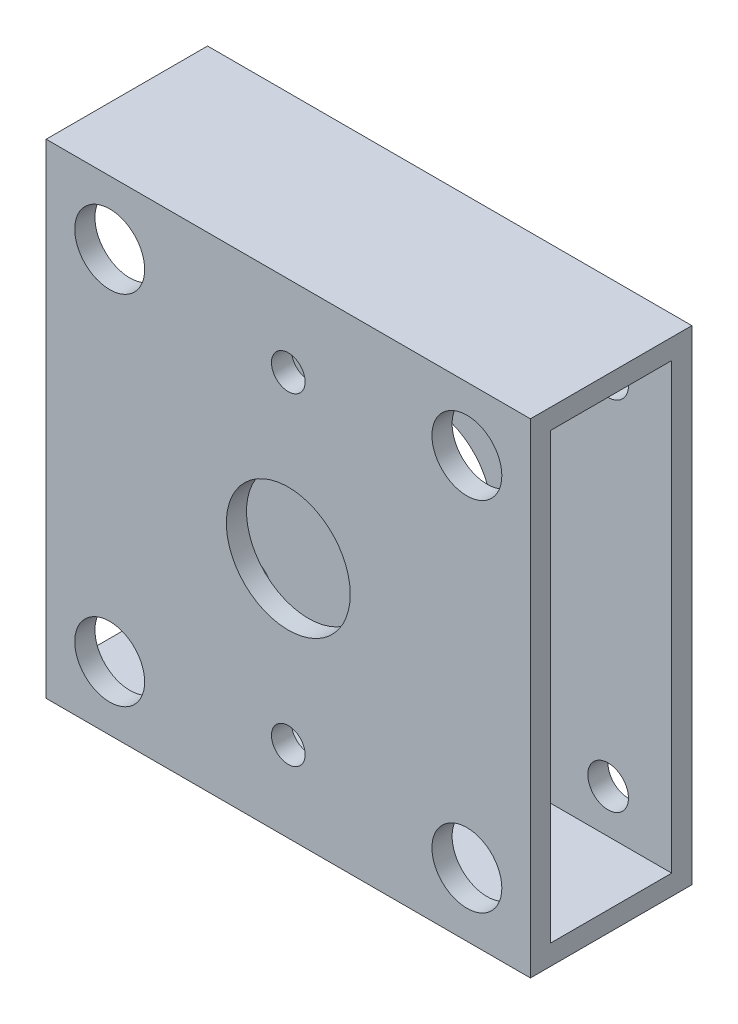
from build123d import *

# Parameters (mm, degrees)
SKETCH1_W                                       = 76.2
SKETCH1_H                                       = 76.2
BOSS_EXTRUDE1_DEPTH                             = 12.7
SKETCH2_W                                       = 19.05
SKETCH2_H                                       = 69.85
CUT_EXTRUDE1_DEPTH                              = 77.2
SKETCH4_R                                       = 9.75
SKETCH4_R_2                                     = 2.2
SKETCH4_R_3                                     = 2.368967754
SKETCH4_R_4                                     = 2.114206927
SKETCH4_R_5                                     = 2.315385773
SKETCH4_R_6                                     = 1.799630575
CUT_EXTRUDE2_DEPTH                              = 26.4
CBORE_FOR_M6_SOCKET_HEAD_CAP_SCREW1_D           = 6.4
CBORE_FOR_M6_SOCKET_HEAD_CAP_SCREW1_CBORE_D     = 11
CBORE_FOR_M6_SOCKET_HEAD_CAP_SCREW1_CBORE_DEPTH = 6.4
CUT_EXTRUDE3_REACH                              = 27.4
SKETCH8_R                                       = 3.81
CBORE_FOR_M5_SOCKET_HEAD_CAP_SCREW3_D           = 5.3
CBORE_FOR_M5_SOCKET_HEAD_CAP_SCREW3_CBORE_D     = 10
CBORE_FOR_M5_SOCKET_HEAD_CAP_SCREW3_CBORE_DEPTH = 5.4


with BuildPart() as part:
    # Sketch1 → Boss-Extrude1 (new body, symmetric)
    with BuildSketch(Plane.XY):
        Rectangle(SKETCH1_W, SKETCH1_H)
    extrude(amount=BOSS_EXTRUDE1_DEPTH, both=True)

    # Sketch2 → Cut-Extrude1 (cut, through all)
    with BuildSketch(Plane(origin=(38.1, 0, 0), x_dir=(0, 0, -1), z_dir=(1, 0, 0))):
        Rectangle(SKETCH2_W, SKETCH2_H)
    extrude(amount=-CUT_EXTRUDE1_DEPTH, mode=Mode.SUBTRACT)

    # Sketch4 → Cut-Extrude2 (cut, through all)
    with BuildSketch(Plane.XY.offset(12.7)):
        Circle(SKETCH4_R)
        with Locations((0, 25.4)):
            Circle(SKETCH4_R_2)
        with Locations((-28.1, 28.1)):
            Circle(SKETCH4_R_3)
        with Locations((28.1, 28.1)):
            Circle(SKETCH4_R_4)
        with Locations((-28.1, -28.1)):
            Circle(SKETCH4_R_5)
        with Locations((28.1, -28.1)):
            Circle(SKETCH4_R_6)
        with Locations((0, -25.4)):
            Circle(SKETCH4_R_2)
    extrude(amount=-CUT_EXTRUDE2_DEPTH, mode=Mode.SUBTRACT)

    # CBORE for M6 Socket Head Cap Screw1 (through all)
    with Locations(Plane.XY.offset(12.7)):
        with Locations((-28.1, 28.1), (28.1, 28.1), (28.1, -28.1), (-28.1, -28.1)):
            CounterBoreHole(CBORE_FOR_M6_SOCKET_HEAD_CAP_SCREW1_D / 2, CBORE_FOR_M6_SOCKET_HEAD_CAP_SCREW1_CBORE_D / 2, CBORE_FOR_M6_SOCKET_HEAD_CAP_SCREW1_CBORE_DEPTH)

    # Sketch8 → Cut-Extrude3 (cut, up to next)
    with BuildSketch(Plane(origin=(0, 0, -12.7), x_dir=(-1, 0, 0), z_dir=(0, 0, -1)), mode=Mode.PRIVATE) as cut_extrude3_sk1:
        with Locations((0, 25.4)):
            Circle(SKETCH8_R)
    cut_extrude3_tool1 = extrude(cut_extrude3_sk1.sketch, amount=-CUT_EXTRUDE3_REACH, mode=Mode.PRIVATE) & part.part
    add(cut_extrude3_tool1.solids().sort_by_distance((0, 25.4, -12.7))[0], mode=Mode.SUBTRACT)
    # Sketch8 → Cut-Extrude3 (cut, up to next)
    with BuildSketch(Plane(origin=(0, 0, -12.7), x_dir=(-1, 0, 0), z_dir=(0, 0, -1)), mode=Mode.PRIVATE) as cut_extrude3_sk2:
        with Locations((0, -25.4)):
            Circle(SKETCH8_R)
    cut_extrude3_tool2 = extrude(cut_extrude3_sk2.sketch, amount=-CUT_EXTRUDE3_REACH, mode=Mode.PRIVATE) & part.part
    add(cut_extrude3_tool2.solids().sort_by_distance((0, -25.4, -12.7))[0], mode=Mode.SUBTRACT)

    # CBORE for M5 Socket Head Cap Screw3 (through all)
    with Locations(Plane(origin=(0, 0, -12.7), x_dir=(-1, 0, 0), z_dir=(0, 0, -1))):
        with Locations((0, -25.4), (0, 25.4)):
            CounterBoreHole(CBORE_FOR_M5_SOCKET_HEAD_CAP_SCREW3_D / 2, CBORE_FOR_M5_SOCKET_HEAD_CAP_SCREW3_CBORE_D / 2, CBORE_FOR_M5_SOCKET_HEAD_CAP_SCREW3_CBORE_DEPTH)


solid = part.part
